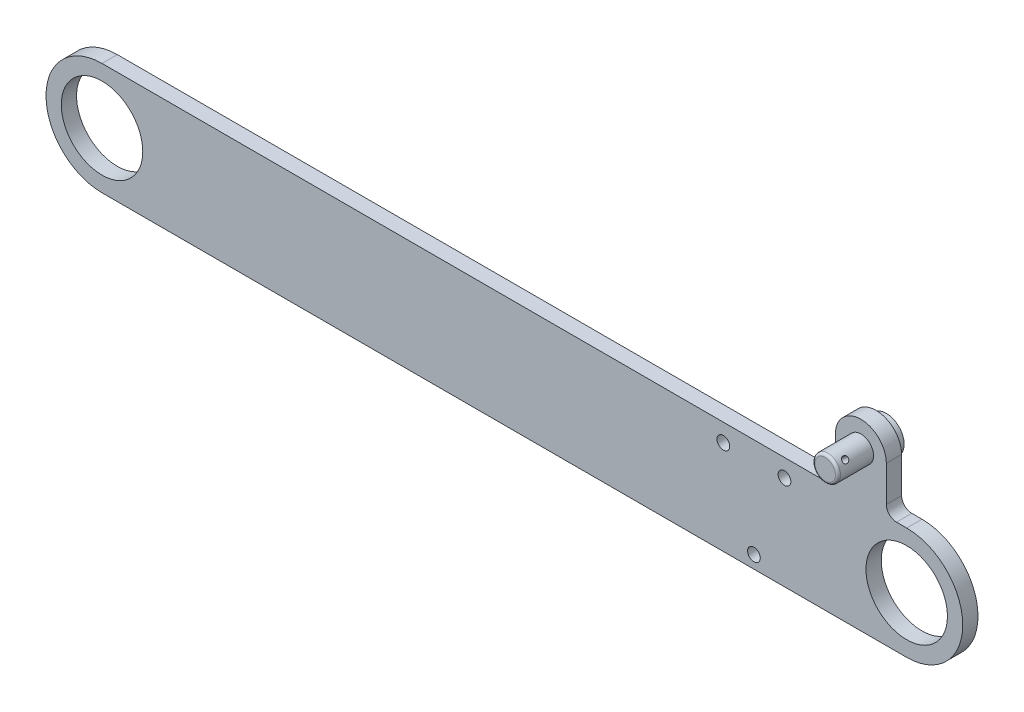
from build123d import *

# Parameters (mm, degrees)
ESQUISSE1_R             = 8
BOSS_EXTRU_1_DEPTH      = 3
ESQUISSE2_R             = 2.5
BOSS_EXTRU_2_DEPTH      = 3
CONG_2_R                = 2
ESQUISSE3_R             = 3.5
BOSS_EXTRU_3_DEPTH      = 2
ESQUISSE4_R             = 2.5
BOSS_EXTRU_4_DEPTH      = 10
CONG_3_R                = 0.5
ESQUISSE5_W             = 0.6
ESQUISSE5_H             = 145.82516777
ESQUISSE6_R             = 1.25
ENL_V_MAT_EXTRU_1_DEPTH = 11


with BuildPart() as part:
    # Esquisse1 → Boss.-Extru.1 (new body)
    with BuildSketch(Plane.XY):
        with BuildLine():
            Line((79, 11), (-79, 11))
            ThreePointArc((-79, 11), (-90, 0), (-79, -11))
            Line((-79, -11), (79, -11))
            ThreePointArc((79, -11), (90, 0), (79, 11))
        make_face()
        with Locations((-79, 0)):
            Circle(ESQUISSE1_R, mode=Mode.SUBTRACT)
        with Locations((79, 0)):
            Circle(ESQUISSE1_R, mode=Mode.SUBTRACT)
    extrude(amount=BOSS_EXTRU_1_DEPTH)

    # Esquisse2 → Boss.-Extru.2 (add)
    with BuildSketch(Plane.XY.offset(3)):
        with BuildLine():
            Line((75, 11), (75, 20))
            ThreePointArc((75, 20), (70, 25), (65, 20))
            Line((65, 20), (65, 11))
            Line((65, 11), (75, 11))
        make_face()
        with Locations((70, 20)):
            Circle(ESQUISSE2_R, mode=Mode.SUBTRACT)
    extrude(amount=-BOSS_EXTRU_2_DEPTH)

    # Congé2
    cong_2_edges = [part.edges().sort_by_distance(p)[0] for p in [
        (65, 11, 1.5),
        (75, 11, 1.5),
    ]]
    fillet(cong_2_edges, radius=CONG_2_R)

    # Esquisse6 → Enlèv. mat.-Extru.1 (cut, through all)
    with BuildSketch(Plane(origin=(0, 0, 0), x_dir=(-1, 0, 0), z_dir=(0, 0, -1))):
        with Locations((-55, 7.5)):
            Circle(ESQUISSE6_R)
        with Locations((-43, 7.5)):
            Circle(ESQUISSE6_R)
        with Locations((-49, -8.5)):
            Circle(ESQUISSE6_R)
    extrude(amount=-ENL_V_MAT_EXTRU_1_DEPTH, mode=Mode.SUBTRACT)


with BuildPart() as body_2:
    # Esquisse3 → Boss.-Extru.3 (new body)
    with BuildSketch(Plane(origin=(0, 0, 0), x_dir=(-1, 0, 0), z_dir=(0, 0, -1))):
        with Locations((-70, 20)):
            Circle(ESQUISSE3_R)
    extrude(amount=BOSS_EXTRU_3_DEPTH)


with BuildPart() as body_3:
    # Esquisse4 → Boss.-Extru.4 (new body)
    with BuildSketch(Plane.XY):
        with Locations((70, 20)):
            Circle(ESQUISSE4_R)
    extrude(amount=BOSS_EXTRU_4_DEPTH)

    # Congé3
    cong_3_edges = [body_3.edges().sort_by_distance(p)[0] for p in [
        (67.5, 20, 10),
    ]]
    fillet(cong_3_edges, radius=CONG_3_R)

    # Esquisse5 → Diamètre du perçage Ø1.2 (1.2)1 (revolve, cut)
    with BuildSketch(Plane(origin=(71.932061944, 21.586548658, 8), x_dir=(-0.634619463, 0.772824778, 0), z_dir=(0, 0, 1))):
        with Locations((0.3, 72.912583885)):
            Rectangle(ESQUISSE5_W, ESQUISSE5_H)
    revolve(axis=Axis((76.839499281, 25.61638225, 8), (-0.772824778, -0.634619463, 0)), mode=Mode.SUBTRACT)


solid = Compound([part.part, body_2.part, body_3.part])
